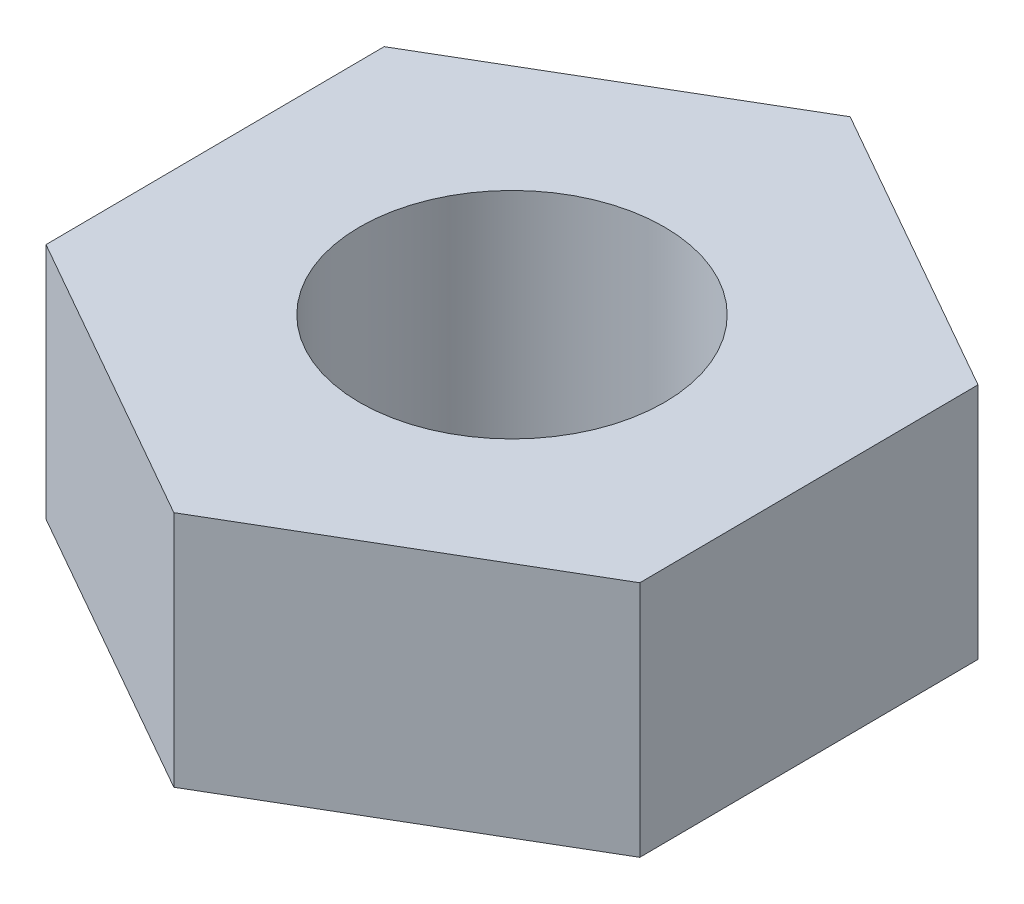
from build123d import *

# Parameters (mm, degrees)
SKETCH1_R      = 2
EXTRUDE1_DEPTH = 3.125


with BuildPart() as part:
    # Sketch1 → Extrude1 (new body)
    with BuildSketch(Plane(origin=(0, 0, 0), x_dir=(1, 0, 0), z_dir=(0, 1, 0))):
        Polygon((3.859462612, 2.263930582), (-0.030890091, 4.474357958), (-3.890352703, 2.210427376), (-3.859462612, -2.263930582), (0.030890091, -4.474357958), (3.890352703, -2.210427376), align=None)
        with Locations(Location((0, 0, 0), (0, 0, 270))):  # turned: the seam where the file's is
            Circle(SKETCH1_R, mode=Mode.SUBTRACT)
    extrude(amount=EXTRUDE1_DEPTH)


solid = part.part
